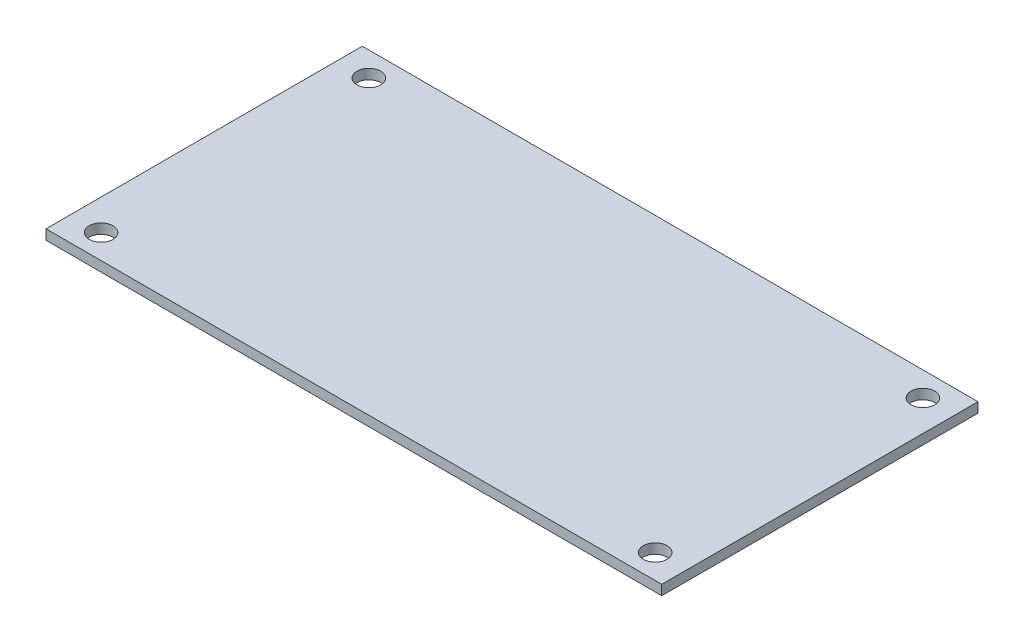
from build123d import *

# Parameters (mm, degrees)
SKETCH1_W           = 98.9
SKETCH1_H           = 50.8
SKETCH1_R           = 1.905
BOSS_EXTRUDE1_DEPTH = 1.6


with BuildPart() as part:
    # Sketch1 → Boss-Extrude1 (new body)
    with BuildSketch(Plane(origin=(0, 0, 0), x_dir=(1, 0, 0), z_dir=(0, 1, 0))):
        with Locations((49.45, 25.4)):
            Rectangle(SKETCH1_W, SKETCH1_H)
        with Locations((4.95, 46.9)):
            Circle(SKETCH1_R, mode=Mode.SUBTRACT)
        with Locations((93.95, 46.9)):
            Circle(SKETCH1_R, mode=Mode.SUBTRACT)
        with Locations((93.95, 3.9)):
            Circle(SKETCH1_R, mode=Mode.SUBTRACT)
        with Locations((4.95, 3.9)):
            Circle(SKETCH1_R, mode=Mode.SUBTRACT)
    extrude(amount=BOSS_EXTRUDE1_DEPTH)


solid = part.part
